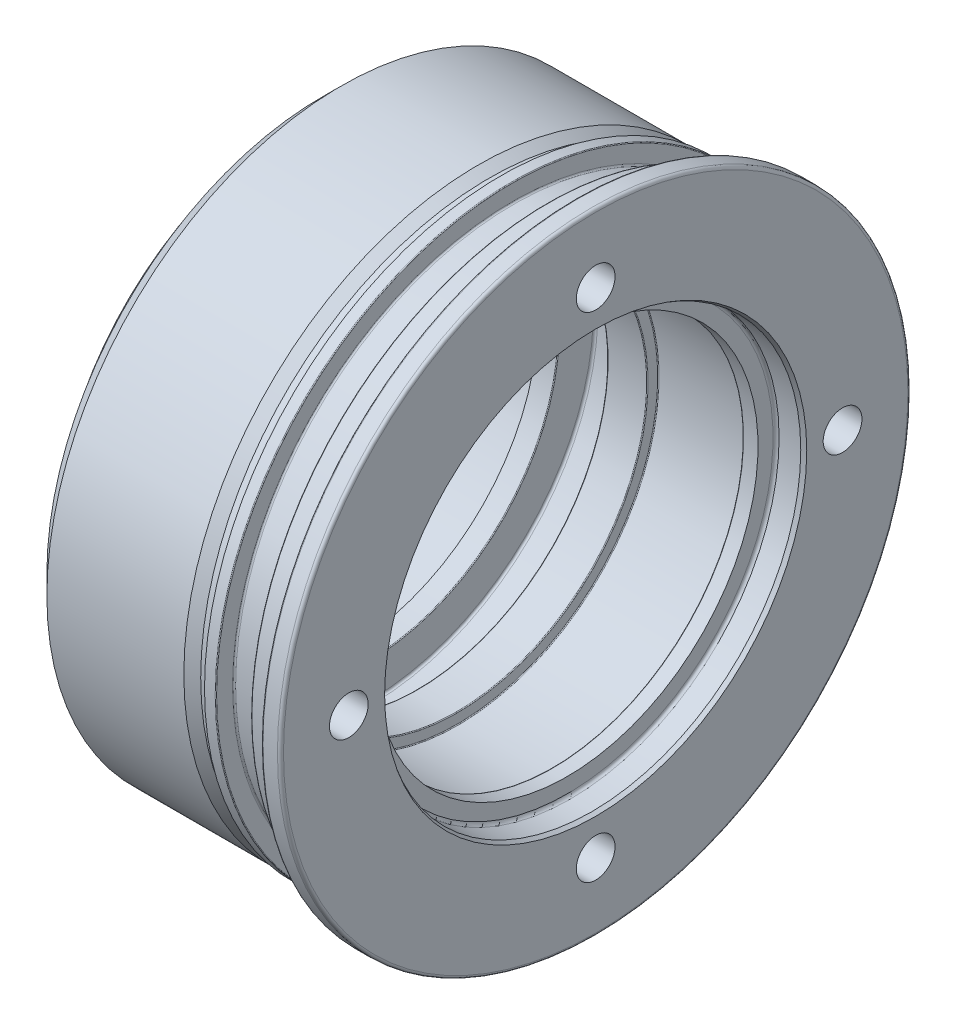
from build123d import *

# Parameters (mm, degrees)
F_4_STK_10_2_X_12_HULLER_D     = 10.2
F_4_STK_10_2_X_12_HULLER_DEPTH = 12
F_4_STK_10_2_X_12_HULLER_TIP   = 3.064389157


with BuildPart() as part:
    # Sketch1 → Base-Revolve (revolve)
    with BuildSketch(Plane.XY):
        with BuildLine():
            Line((0, 55.577350269), (0, 82.2))
            ThreePointArc((0, 82.2), (-0.234314575, 82.765685425), (-0.8, 83))
            Line((-0.8, 83), (-4.6, 83))
            ThreePointArc((-4.6, 83), (-4.882842712, 82.882842712), (-5, 82.6))
            Line((-5, 82.6), (-5, 78.8))
            ThreePointArc((-5, 78.8), (-5.234314575, 78.234314575), (-5.8, 78))
            Line((-5.8, 78), (-12.5, 78))
            ThreePointArc((-12.5, 78), (-12.641421356, 77.941421356), (-12.7, 77.8))
            Line((-12.7, 77.8), (-12.7, 73.6))
            ThreePointArc((-12.7, 73.6), (-12.817157288, 73.317157288), (-13.1, 73.2))
            Line((-13.1, 73.2), (-21.6, 73.2))
            ThreePointArc((-21.6, 73.2), (-21.882842712, 73.317157288), (-22, 73.6))
            Line((-22, 73.6), (-22, 77.8))
            ThreePointArc((-22, 77.8), (-22.058578644, 77.941421356), (-22.2, 78))
            Line((-22.2, 78), (-25, 78))
            Line((-25, 78), (-25, 76))
            Line((-25, 76), (-28, 76))
            Line((-28, 76), (-30.943915758, 77.5))
            Line((-30.943915758, 77.5), (-67, 77.5))
            Line((-67, 77.5), (-72, 72.5))
            Line((-72, 72.5), (-72, 65))
            Line((-72, 65), (-77.5, 65))
            Line((-77.5, 65), (-77.5, 52))
            Line((-77.5, 52), (-65.5, 52))
            Line((-65.5, 52), (-65.5, 50.25))
            Line((-65.5, 50.25), (-60.2, 50.25))
            ThreePointArc((-60.2, 50.25), (-60.058578644, 50.308578644), (-60, 50.45))
            Line((-60, 50.45), (-60, 59.4))
            ThreePointArc((-60, 59.4), (-59.824264069, 59.824264069), (-59.4, 60))
            Line((-59.4, 60), (-47.6, 60))
            ThreePointArc((-47.6, 60), (-47.175735931, 59.824264069), (-47, 59.4))
            Line((-47, 59.4), (-47, 50.3))
            ThreePointArc((-47, 50.3), (-46.941421356, 50.158578644), (-46.8, 50.1))
            Line((-46.8, 50.1), (-36.7, 50.1))
            ThreePointArc((-36.7, 50.1), (-36.558578644, 50.158578644), (-36.5, 50.3))
            Line((-36.5, 50.3), (-36.5, 52.8))
            ThreePointArc((-36.5, 52.8), (-36.441421356, 52.941421356), (-36.3, 53))
            Line((-36.3, 53), (-11.7, 53))
            ThreePointArc((-11.7, 53), (-11.558578644, 52.941421356), (-11.5, 52.8))
            Line((-11.5, 52.8), (-11.5, 50.45))
            ThreePointArc((-11.5, 50.45), (-11.441421356, 50.308578644), (-11.3, 50.25))
            Line((-11.3, 50.25), (-7.5, 50.25))
            Line((-7.5, 50.25), (-7.5, 54.2))
            ThreePointArc((-7.5, 54.2), (-7.265685425, 54.765685425), (-6.7, 55))
            Line((-6.7, 55), (-1, 55))
            Line((-1, 55), (0, 55.577350269))
        make_face()
    revolve(axis=Axis((-77.5, 0, 0), (1, 0, 0)))

    # 4 stk ø10.2 x 12 huller
    with Locations(Plane(origin=(0, 0, 0), x_dir=(0, 0, -1), z_dir=(1, 0, 0))):
        with Locations((0, 65), (65, 0), (0, -65), (-65, 0)):
            Hole(F_4_STK_10_2_X_12_HULLER_D / 2, depth=F_4_STK_10_2_X_12_HULLER_DEPTH)
            with Locations((0, 0, -(F_4_STK_10_2_X_12_HULLER_DEPTH + F_4_STK_10_2_X_12_HULLER_TIP / 2))):  # 118° drill point
                Cone(0, F_4_STK_10_2_X_12_HULLER_D / 2, F_4_STK_10_2_X_12_HULLER_TIP, mode=Mode.SUBTRACT)


solid = part.part
